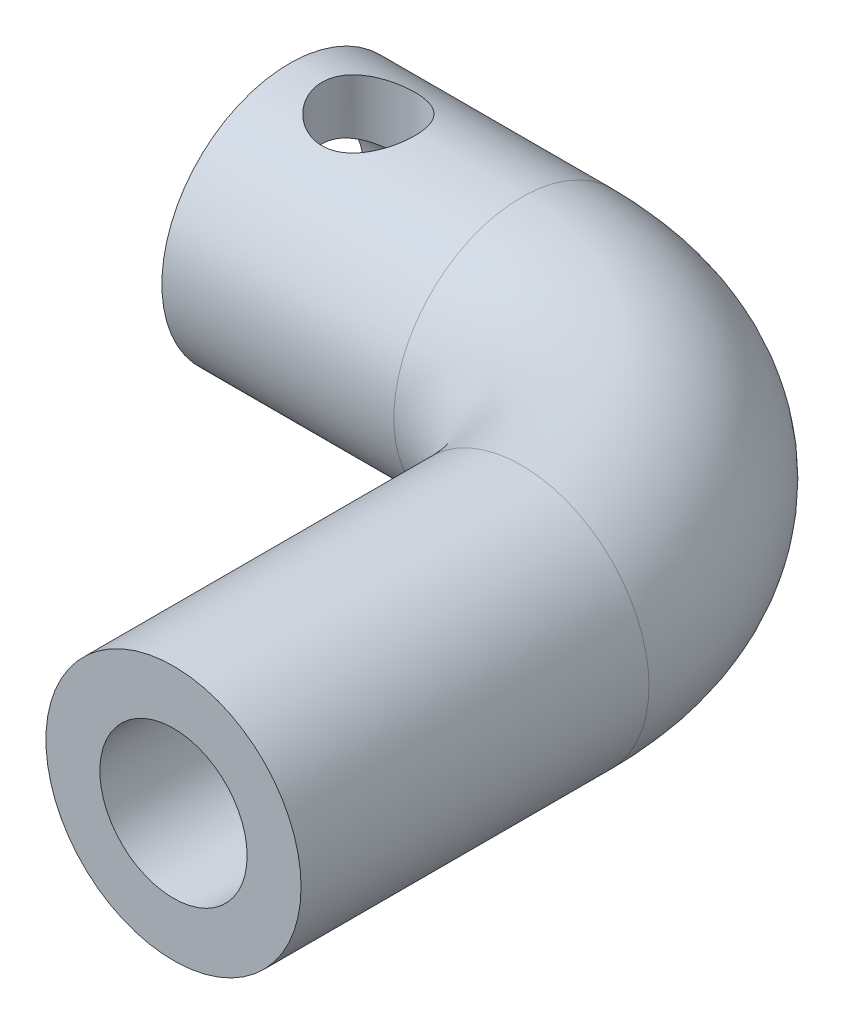
from build123d import *

# Parameters (mm, degrees)
SKETCH4_R           = 5.5
SKETCH6_R           = 3.175
HOLE_SHAFT_DEPTH    = 10
SKETCH7_R           = 3.2
HOLE_POT_DEPTH      = 10
SKETCH8_R           = 2
CUT_EXTRUDE3_DEPTH  = 32.008063485
SKETCH11_W          = 6.737911532
SKETCH11_H          = 1
BOSS_EXTRUDE2_DEPTH = 1


with BuildPart() as part:
    # Sweep2: sweep along a path in PROFILE
    with BuildLine(Plane(origin=(0, 0, 0), x_dir=(1, 0, 0), z_dir=(0, 1, 0))) as sweep2_path:
        Line((2.5, -25), (2.5, -10))
        ThreePointArc((2.5, -10), (-0.428932188, -2.928932188), (-7.5, 0))
        Line((-7.5, 0), (-17.5, 0))
    # Sketch4 → Sweep2 (sweep)
    with BuildSketch(Plane.XY.offset(25)):
        with Locations((2.5, 0)):
            Circle(SKETCH4_R)
    sweep(path=sweep2_path.line)

    # Sketch6 → HOLE_SHAFT (cut)
    with BuildSketch(Plane.XY.offset(25)):
        with Locations((2.5, 0)):
            Circle(SKETCH6_R)
    extrude(amount=-HOLE_SHAFT_DEPTH, mode=Mode.SUBTRACT)

    # Sketch7 → HOLE_POT (cut)
    with BuildSketch(Plane.ZY.offset(17.5)):
        Circle(SKETCH7_R)
    extrude(amount=-HOLE_POT_DEPTH, mode=Mode.SUBTRACT)

    # Sketch8 → Cut-Extrude3 (cut, through all)
    with BuildSketch(Plane(origin=(0, 0, 0), x_dir=(1, 0, 0), z_dir=(0, 1, 0))):
        with Locations((-14.096251262, 0)):
            Circle(SKETCH8_R)
    extrude(amount=CUT_EXTRUDE3_DEPTH, mode=Mode.SUBTRACT)

    # Sketch11 → Boss-Extrude2 (add)
    with BuildSketch(Plane.ZY.offset(7.5)):
        Rectangle(SKETCH11_W, SKETCH11_H)
    extrude(amount=BOSS_EXTRUDE2_DEPTH)


solid = part.part
